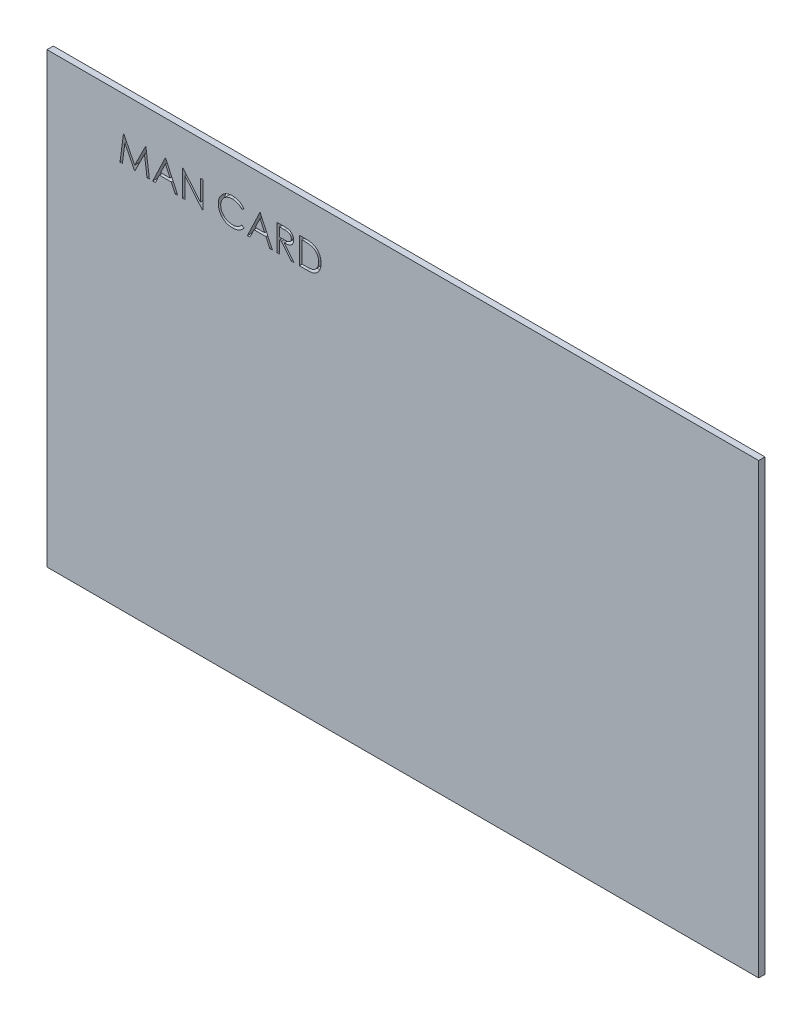
from build123d import *

# Parameters (mm, degrees)
SKETCH1_W           = 85.725
SKETCH1_H           = 53.975
BOSS_EXTRUDE1_DEPTH = 0.75946
CUT_EXTRUDE1_DEPTH  = 0.75946


with BuildPart() as part:
    # Sketch1 → Boss-Extrude1 (new body)
    with BuildSketch(Plane.XY):
        with Locations((-55.690706651, 13.736965558)):
            Rectangle(SKETCH1_W, SKETCH1_H)
    extrude(amount=BOSS_EXTRUDE1_DEPTH)

    # Sketch2 → Cut-Extrude1 (cut)
    with BuildSketch(Plane.XY.offset(0.75946)):
        Polygon((-89.760898959, 33.389305045), (-89.341763342, 36.564305045), (-89.301058213, 36.564305045), (-87.990225882, 33.95917684), (-86.682573638, 36.564305045), (-86.641232492, 36.564305045), (-86.219552805, 33.389305045), (-86.505760737, 33.389305045), (-86.809777164, 35.673880366), (-87.95588093, 33.389305045), (-88.02011871, 33.389305045), (-89.1706746, 35.678968507), (-89.474055008, 33.389305045), align=None)
        Polygon((-84.265706651, 36.564305045), (-82.800322035, 33.389305045), (-83.11006262, 33.389305045), (-83.57944363, 34.40693325), (-85.018751523, 34.40693325), (-85.501488902, 33.389305045), (-85.812501523, 33.389305045), (-84.306411779, 36.564305045), align=None)
        Polygon((-84.289239303, 35.945459893), (-84.864199239, 34.732574276), (-83.72954379, 34.732574276), align=None, mode=Mode.SUBTRACT)
        Polygon((-82.230450241, 33.389305045), (-82.230450241, 36.564305045), (-82.170664584, 36.564305045), (-80.073078446, 34.065391784), (-80.073078446, 36.564305045), (-79.788142548, 36.564305045), (-79.788142548, 33.389305045), (-79.853016346, 33.389305045), (-81.945514343, 35.882494148), (-81.945514343, 33.389305045), align=None)
        with BuildLine():
            Line((-74.822116907, 35.981712898), (-75.071435817, 35.790907609))
            add(Edge.make_bspline(
                [(-75.071435817, 35.790907609), (-75.089221159, 35.812103882), (-75.124552057, 35.854210655), (-75.181392905, 35.913337814), (-75.240630824, 35.968732729), (-75.30224317, 36.020659291), (-75.367338943, 36.067301643), (-75.434341238, 36.111090429), (-75.504370894, 36.150340449), (-75.601209967, 36.197931872), (-75.727890515, 36.247594455), (-75.887361548, 36.289235244), (-76.05383233, 36.315743025), (-76.167404438, 36.318613988), (-76.225171795, 36.320074276)],
                knots=[0, 0, 0, 0, 0.757959112, 1.505699292, 2.245454638, 2.979532153, 3.711538275, 4.438200793, 5.171680507, 5.909471876, 7.393775596, 8.890124382, 10.418191784, 12, 12, 12, 12], degree=3))
            add(Edge.make_bspline(
                [(-76.225171795, 36.320074276), (-76.256997359, 36.319707824), (-76.320353117, 36.318978322), (-76.414377089, 36.30935433), (-76.506645357, 36.295827732), (-76.597097902, 36.275756903), (-76.685619585, 36.250381741), (-76.772789122, 36.220060116), (-76.857344451, 36.182545368), (-76.940455282, 36.141081447), (-77.020083566, 36.094247979), (-77.095426359, 36.043163724), (-77.166208873, 35.988400329), (-77.2324871, 35.92975254), (-77.294328796, 35.867484476), (-77.351285856, 35.800932538), (-77.403161193, 35.730309494), (-77.450983066, 35.656546618), (-77.493811759, 35.579858764), (-77.529671007, 35.499962093), (-77.561425654, 35.418224799), (-77.586552824, 35.333723389), (-77.606441493, 35.247052451), (-77.620164444, 35.157979379), (-77.629678986, 35.066690256), (-77.630404861, 35.004814665), (-77.630770753, 34.973624957)],
                knots=[0, 0, 0, 0, 1.054917814, 2.100044995, 3.131103042, 4.146048494, 5.169673617, 6.183595914, 7.203665975, 8.234915748, 9.262203917, 10.264457458, 11.251630812, 12.227803204, 13.197192746, 14.159520551, 15.12972552, 16.100847026, 17.073214652, 18.039054194, 19.002613845, 19.979014051, 20.95965708, 21.949030935, 22.966165397, 24, 24, 24, 24], degree=3))
            add(Edge.make_bspline(
                [(-77.630770753, 34.973624957), (-77.629626103, 34.92669726), (-77.627378735, 34.83456095), (-77.607377746, 34.699604754), (-77.576983842, 34.570318142), (-77.53143114, 34.447509286), (-77.475261715, 34.329663846), (-77.404286303, 34.218775744), (-77.322084159, 34.113169289), (-77.227492364, 34.015340329), (-77.123709945, 33.925974307), (-77.012360054, 33.847279136), (-76.893720021, 33.781679207), (-76.769099793, 33.727091027), (-76.637540389, 33.685129567), (-76.49927839, 33.655589255), (-76.354614509, 33.636319563), (-76.255763696, 33.634474717), (-76.205455249, 33.633535814)],
                knots=[0, 0, 0, 0, 1.029171465, 2.020641659, 2.987623507, 3.938342917, 4.889210282, 5.84687017, 6.821220943, 7.821438502, 8.827599549, 9.822697543, 10.807740252, 11.797342354, 12.80366471, 13.83203677, 14.896651826, 16, 16, 16, 16], degree=3))
            add(Edge.make_bspline(
                [(-76.205455249, 33.633535814), (-76.150026381, 33.635067779), (-76.040929109, 33.638083051), (-75.880938114, 33.663627513), (-75.727779955, 33.705045767), (-75.581446394, 33.763010311), (-75.442349965, 33.838362393), (-75.310272995, 33.929709754), (-75.185103999, 34.037921313), (-75.109837193, 34.120546722), (-75.071435817, 34.162702481)],
                knots=[0, 0, 0, 0, 1.028121516, 2.023589091, 2.998037872, 3.967518031, 4.937445131, 5.927275754, 6.942489185, 8, 8, 8, 8], degree=3))
            Line((-75.071435817, 34.162702481), (-74.822116907, 33.973805245))
            add(Edge.make_bspline(
                [(-74.822116907, 33.973805245), (-74.842181193, 33.947916793), (-74.882213657, 33.896263891), (-74.947036286, 33.823445983), (-75.015323549, 33.754953037), (-75.087582657, 33.691337266), (-75.162982368, 33.631325715), (-75.242876537, 33.576623339), (-75.326214874, 33.526466609), (-75.412715008, 33.480540756), (-75.502285036, 33.439794396), (-75.59481763, 33.404911335), (-75.689913938, 33.374862328), (-75.787578306, 33.350140928), (-75.888013314, 33.330845017), (-75.99085653, 33.31794574), (-76.096329917, 33.309108432), (-76.167487492, 33.308302966), (-76.203547196, 33.307894789)],
                knots=[0, 0, 0, 0, 0.986787822, 1.968848986, 2.935600012, 3.899624008, 4.868462664, 5.837806735, 6.815139263, 7.798259679, 8.787526145, 9.778297419, 10.776456485, 11.791383307, 12.812564526, 13.85620153, 14.913611965, 16, 16, 16, 16], degree=3))
            add(Edge.make_bspline(
                [(-76.203547196, 33.307894789), (-76.237695379, 33.308132453), (-76.305219184, 33.308602406), (-76.404913052, 33.3162153), (-76.501967886, 33.326601848), (-76.596106296, 33.342241109), (-76.687842002, 33.360696332), (-76.776343389, 33.385435258), (-76.86248133, 33.413147716), (-76.945909754, 33.445718668), (-77.026699624, 33.482472634), (-77.104590367, 33.524012119), (-77.17954616, 33.569987811), (-77.252303934, 33.619386285), (-77.321788885, 33.673794266), (-77.388603155, 33.732456141), (-77.453121401, 33.795174194), (-77.493038122, 33.840399668), (-77.513107492, 33.863138178)],
                knots=[0, 0, 0, 0, 1.114604814, 2.203992996, 3.262667896, 4.300477797, 5.318619304, 6.316056647, 7.298880507, 8.271930387, 9.238335007, 10.195173496, 11.151986948, 12.108099108, 13.064862484, 14.031167946, 15.010108607, 16, 16, 16, 16], degree=3))
            add(Edge.make_bspline(
                [(-77.513107492, 33.863138178), (-77.545252683, 33.902636257), (-77.60915498, 33.981155558), (-77.69091185, 34.108414984), (-77.760895704, 34.241282573), (-77.817479575, 34.380456366), (-77.86171434, 34.525624067), (-77.89235871, 34.676858855), (-77.912271951, 34.834019489), (-77.914549141, 34.94091429), (-77.915706651, 34.995249556)],
                knots=[0, 0, 0, 0, 0.994628077, 1.977248131, 2.950237994, 3.925870899, 4.908910175, 5.911660606, 6.938484602, 8, 8, 8, 8], degree=3))
            add(Edge.make_bspline(
                [(-77.915706651, 34.995249556), (-77.914295868, 35.052359146), (-77.911520241, 35.164718699), (-77.887938341, 35.329613643), (-77.850002719, 35.48759384), (-77.796121256, 35.63836438), (-77.727808544, 35.782718277), (-77.643420116, 35.919552798), (-77.543936351, 36.049743038), (-77.430137486, 36.171313563), (-77.30534426, 36.282474261), (-77.171705051, 36.380269889), (-77.029481427, 36.461656492), (-76.880240233, 36.529688726), (-76.722863936, 36.581980489), (-76.557688309, 36.618586594), (-76.385023722, 36.641371406), (-76.26721995, 36.644251773), (-76.207363301, 36.645715301)],
                knots=[0, 0, 0, 0, 1.032925535, 2.032216505, 3.007276963, 3.968222605, 4.92396291, 5.891752235, 6.871517503, 7.883894988, 8.900124299, 9.891468569, 10.874487609, 11.85992873, 12.854644235, 13.869047385, 14.917252991, 16, 16, 16, 16], degree=3))
            add(Edge.make_bspline(
                [(-76.207363301, 36.645715301), (-76.17088303, 36.645277933), (-76.098674008, 36.644412207), (-75.99185553, 36.635970207), (-75.887858562, 36.621897149), (-75.786611457, 36.602741858), (-75.687621655, 36.578968073), (-75.591645723, 36.547997945), (-75.498120485, 36.512586235), (-75.40763579, 36.471802484), (-75.320625777, 36.42602194), (-75.237117545, 36.375752052), (-75.157774423, 36.321055143), (-75.082038111, 36.262396405), (-75.011175548, 36.198534855), (-74.943174778, 36.131227036), (-74.880345085, 36.05853421), (-74.84156183, 36.007366877), (-74.822116907, 35.981712898)],
                knots=[0, 0, 0, 0, 1.096760587, 2.17092713, 3.219439832, 4.250915756, 5.268269357, 6.278326846, 7.281116186, 8.274029601, 9.260640565, 10.235837813, 11.203064059, 12.156899882, 13.114053108, 14.069676657, 15.032185724, 16, 16, 16, 16], degree=3))
        make_face()
        Polygon((-72.868270753, 36.564305045), (-71.402886138, 33.389305045), (-71.712626723, 33.389305045), (-72.182007733, 34.40693325), (-73.621315625, 34.40693325), (-74.104053005, 33.389305045), (-74.415065625, 33.389305045), (-72.908975882, 36.564305045), align=None)
        Polygon((-72.891803406, 35.945459893), (-73.466763342, 34.732574276), (-72.332107893, 34.732574276), align=None, mode=Mode.SUBTRACT)
        with BuildLine():
            Line((-70.833014343, 36.564305045), (-70.197632733, 36.564305045))
            add(Edge.make_bspline(
                [(-70.197632733, 36.564305045), (-70.155231852, 36.564163906), (-70.073817464, 36.563892904), (-69.95718314, 36.562381819), (-69.851204273, 36.558050797), (-69.755936276, 36.554323725), (-69.671380896, 36.547527464), (-69.597278854, 36.541031734), (-69.533971443, 36.532528484), (-69.49564842, 36.524631422), (-69.478296795, 36.521055846)],
                knots=[0, 0, 0, 0, 1.410062039, 2.707475311, 3.878576406, 4.937260626, 5.877586885, 6.699081471, 7.410979367, 8, 8, 8, 8], degree=3))
            add(Edge.make_bspline(
                [(-69.478296795, 36.521055846), (-69.455067929, 36.515316566), (-69.409105731, 36.503960441), (-69.3429296, 36.479957803), (-69.279870178, 36.452181429), (-69.220189408, 36.419557197), (-69.164186226, 36.381842933), (-69.111283187, 36.339689707), (-69.061240231, 36.293328171), (-69.016081181, 36.241589422), (-68.973500755, 36.187309159), (-68.937588216, 36.128613608), (-68.906630623, 36.067234937), (-68.881983083, 36.002548922), (-68.862136636, 35.935182886), (-68.848142833, 35.864526621), (-68.839750684, 35.790902022), (-68.838896286, 35.74068449), (-68.838463061, 35.715221511)],
                knots=[0, 0, 0, 0, 1.027469482, 2.033020251, 3.019912614, 3.986113645, 4.951240523, 5.91722682, 6.890402269, 7.87763091, 8.8651537, 9.85103654, 10.82876324, 11.815024772, 12.821070561, 13.842952187, 14.906261191, 16, 16, 16, 16], degree=3))
            add(Edge.make_bspline(
                [(-68.838463061, 35.715221511), (-68.839795652, 35.672916809), (-68.842395883, 35.590369378), (-68.86663937, 35.470571293), (-68.906350927, 35.358820986), (-68.961072768, 35.255259165), (-69.030759006, 35.161904508), (-69.114510781, 35.079907452), (-69.212374814, 35.011291246), (-69.303478551, 34.963709058), (-69.383955003, 34.933235491), (-69.450206651, 34.911793937), (-69.522475981, 34.895227726), (-69.600070563, 34.880386749), (-69.683313308, 34.869181998), (-69.772004701, 34.860975444), (-69.866207995, 34.855846414), (-69.930922723, 34.855082596), (-69.964214263, 34.85468966)],
                knots=[0, 0, 0, 0, 1.260483769, 2.459530307, 3.627416485, 4.787058657, 5.939039949, 7.08810263, 8.267026773, 9.491475466, 10.141966685, 10.831826277, 11.566392101, 12.351337768, 13.187381173, 14.07005841, 15.007169909, 16, 16, 16, 16], degree=3))
            Line((-69.964214263, 34.85468966), (-68.797757933, 33.389305045))
            Line((-68.797757933, 33.389305045), (-69.150111699, 33.389305045))
            Line((-69.150111699, 33.389305045), (-70.316568029, 34.85468966))
            Line((-70.316568029, 34.85468966), (-70.548078446, 34.85468966))
            Line((-70.548078446, 34.85468966), (-70.548078446, 33.389305045))
            Line((-70.548078446, 33.389305045), (-70.833014343, 33.389305045))
            Line((-70.833014343, 33.389305045), (-70.833014343, 36.564305045))
        make_face()
        with BuildLine():
            Line((-70.548078446, 36.238664019), (-70.548078446, 35.180330686))
            Line((-70.548078446, 35.180330686), (-69.966758334, 35.175878563))
            add(Edge.make_bspline(
                [(-69.966758334, 35.175878563), (-69.939616584, 35.175866555), (-69.887008143, 35.175843281), (-69.810898254, 35.179466207), (-69.740032153, 35.183587645), (-69.674680899, 35.189891695), (-69.614815298, 35.198016131), (-69.560465274, 35.208178838), (-69.511542105, 35.220018924), (-69.454484145, 35.238344684), (-69.390769578, 35.267378715), (-69.321526039, 35.309620275), (-69.262559633, 35.362750833), (-69.212741286, 35.423505325), (-69.172709587, 35.490303922), (-69.14448651, 35.562345914), (-69.126577294, 35.637812578), (-69.124464971, 35.68968129), (-69.123398959, 35.715857529)],
                knots=[0, 0, 0, 0, 1.146690395, 2.22261258, 3.21895312, 4.145990853, 4.996080663, 5.770904154, 6.481378293, 7.121626537, 8.300444488, 9.431385265, 10.535395872, 11.636531494, 12.74115979, 13.810798291, 14.895190096, 16, 16, 16, 16], degree=3))
            add(Edge.make_bspline(
                [(-69.123398959, 35.715857529), (-69.124489454, 35.741390492), (-69.126650418, 35.791987509), (-69.14429323, 35.866061085), (-69.174128597, 35.935971818), (-69.214335199, 36.001435315), (-69.263320146, 36.060858375), (-69.320758448, 36.11170115), (-69.385079589, 36.153656021), (-69.445197034, 36.180466067), (-69.498930926, 36.196903362), (-69.545584975, 36.208470489), (-69.598300387, 36.217763686), (-69.657333124, 36.22520957), (-69.722431175, 36.231609412), (-69.793923694, 36.235919954), (-69.871336345, 36.238472531), (-69.924991061, 36.238598704), (-69.952765946, 36.238664019)],
                knots=[0, 0, 0, 0, 1.101028733, 2.181837193, 3.264309656, 4.369019818, 5.486613113, 6.575447106, 7.666700264, 8.788928104, 9.402425223, 10.0903467, 10.862060571, 11.710948788, 12.657782767, 13.684531032, 14.801375019, 16, 16, 16, 16], degree=3))
            Line((-69.952765946, 36.238664019), (-70.548078446, 36.238664019))
        make_face(mode=Mode.SUBTRACT)
        with BuildLine():
            Line((-68.146475882, 33.389305045), (-68.146475882, 36.564305045))
            Line((-68.146475882, 36.564305045), (-67.505370112, 36.564305045))
            add(Edge.make_bspline(
                [(-67.505370112, 36.564305045), (-67.449608959, 36.563903571), (-67.3418787, 36.563127925), (-67.186201694, 36.558209948), (-67.042162138, 36.549510026), (-66.910233759, 36.53683767), (-66.790054374, 36.521277418), (-66.681960494, 36.50177348), (-66.585393193, 36.478742782), (-66.526003057, 36.459107267), (-66.497918189, 36.449821872)],
                knots=[0, 0, 0, 0, 1.314313732, 2.53924729, 3.670748893, 4.714932338, 5.66265055, 6.526160246, 7.303039223, 8, 8, 8, 8], degree=3))
            add(Edge.make_bspline(
                [(-66.497918189, 36.449821872), (-66.461183676, 36.435824018), (-66.388547666, 36.408145734), (-66.285126919, 36.355933946), (-66.187767482, 36.296776347), (-66.095947258, 36.230594957), (-66.011763651, 36.155515869), (-65.931927916, 36.07472837), (-65.859705988, 35.985294662), (-65.793567748, 35.889069494), (-65.733936114, 35.787186418), (-65.682102736, 35.679839569), (-65.639055184, 35.567574102), (-65.6033199, 35.450702218), (-65.575156328, 35.328966932), (-65.55594129, 35.202226497), (-65.543267606, 35.070981803), (-65.541993931, 34.98192354), (-65.541347676, 34.936735934)],
                knots=[0, 0, 0, 0, 0.984719456, 1.947108742, 2.898477687, 3.838006223, 4.779231079, 5.722358779, 6.681677486, 7.655904652, 8.64651281, 9.637519902, 10.640069247, 11.656948941, 12.698408672, 13.768548281, 14.867775369, 16, 16, 16, 16], degree=3))
            add(Edge.make_bspline(
                [(-65.541347676, 34.936735934), (-65.54191824, 34.897491811), (-65.543042595, 34.820157167), (-65.553138474, 34.706182926), (-65.567812707, 34.5955899), (-65.590531372, 34.488904729), (-65.618110795, 34.385192703), (-65.653456847, 34.285559167), (-65.693947618, 34.18909014), (-65.741164294, 34.097090001), (-65.792999693, 34.009928657), (-65.848627274, 33.927763713), (-65.907987705, 33.851767619), (-65.971647029, 33.781710235), (-66.038782601, 33.717697175), (-66.109833958, 33.659193704), (-66.184984439, 33.607344543), (-66.263897452, 33.560112238), (-66.348875084, 33.518909487), (-66.441526905, 33.484047978), (-66.542248045, 33.455158548), (-66.650791278, 33.43105495), (-66.767344147, 33.411934826), (-66.892020923, 33.39912017), (-67.02463005, 33.390454295), (-67.115688383, 33.389695567), (-67.162556611, 33.389305045)],
                knots=[0, 0, 0, 0, 1.105936401, 2.179363191, 3.223086493, 4.248585256, 5.251745608, 6.245858792, 7.225916811, 8.198733463, 9.158002045, 10.082870192, 10.993790845, 11.873723703, 12.748670949, 13.606408763, 14.465103618, 15.319838547, 16.196477973, 17.123216899, 18.106603292, 19.147568657, 20.255746949, 21.433717677, 22.679120308, 24, 24, 24, 24], degree=3))
            Line((-67.162556611, 33.389305045), (-68.146475882, 33.389305045))
        make_face()
        with BuildLine():
            Line((-67.861539984, 33.714946071), (-67.497101883, 33.714946071))
            add(Edge.make_bspline(
                [(-67.497101883, 33.714946071), (-67.444734004, 33.71517113), (-67.344011394, 33.715604), (-67.199178782, 33.719402392), (-67.06684533, 33.725609006), (-66.946992246, 33.73429497), (-66.839687203, 33.745787213), (-66.744705944, 33.758600518), (-66.662359817, 33.77456392), (-66.61253097, 33.789033719), (-66.589504728, 33.795720309)],
                knots=[0, 0, 0, 0, 1.375205317, 2.645023457, 3.804390687, 4.853969522, 5.800190428, 6.637939096, 7.370582563, 8, 8, 8, 8], degree=3))
            add(Edge.make_bspline(
                [(-66.589504728, 33.795720309), (-66.560522999, 33.80592708), (-66.50325177, 33.826096833), (-66.420809643, 33.862888426), (-66.343922932, 33.906469446), (-66.271251694, 33.954912937), (-66.2038268, 34.009927525), (-66.140849209, 34.070316922), (-66.082445717, 34.136388468), (-66.029219738, 34.208060157), (-65.981587205, 34.284885901), (-65.940338304, 34.366110414), (-65.904187272, 34.450843735), (-65.87581312, 34.540387043), (-65.853573983, 34.633939832), (-65.83782173, 34.731508682), (-65.82801123, 34.833075374), (-65.826866917, 34.902156229), (-65.826283574, 34.937371952)],
                knots=[0, 0, 0, 0, 0.998632004, 1.973411704, 2.929992603, 3.868527914, 4.809262121, 5.754881198, 6.702106254, 7.672490631, 8.653608572, 9.636854334, 10.631411391, 11.644891563, 12.686317036, 13.754757253, 14.855430412, 16, 16, 16, 16], degree=3))
            add(Edge.make_bspline(
                [(-65.826283574, 34.937371952), (-65.826749199, 34.974504466), (-65.827663923, 35.047451619), (-65.839161333, 35.154486036), (-65.85596303, 35.257429197), (-65.88025966, 35.356287989), (-65.911221243, 35.45125528), (-65.949860668, 35.541805835), (-65.994008244, 35.628895966), (-66.046534842, 35.71051557), (-66.104061845, 35.787707176), (-66.167904635, 35.858423421), (-66.237048913, 35.922825393), (-66.310740526, 35.981916055), (-66.391056324, 36.033318104), (-66.476104315, 36.079298165), (-66.567132173, 36.118319723), (-66.630462262, 36.13907412), (-66.662646755, 36.149621551)],
                knots=[0, 0, 0, 0, 1.122418816, 2.205001699, 3.251619955, 4.274784885, 5.280384055, 6.268708349, 7.249350384, 8.229342522, 9.199999885, 10.157847722, 11.105861043, 12.055065948, 13.010012805, 13.98527497, 14.976112212, 16, 16, 16, 16], degree=3))
            add(Edge.make_bspline(
                [(-66.662646755, 36.149621551), (-66.689272438, 36.156984311), (-66.745885945, 36.172639558), (-66.838268887, 36.18971686), (-66.942241201, 36.204779513), (-67.058264501, 36.217532163), (-67.186206532, 36.226682804), (-67.326165692, 36.233551068), (-67.478202476, 36.238183513), (-67.583596632, 36.238499841), (-67.638297797, 36.238664019)],
                knots=[0, 0, 0, 0, 0.674548936, 1.434276114, 2.292660221, 3.240891867, 4.284742987, 5.42552168, 6.663806718, 8, 8, 8, 8], degree=3))
            Line((-67.638297797, 36.238664019), (-67.861539984, 36.238664019))
            Line((-67.861539984, 36.238664019), (-67.861539984, 33.714946071))
        make_face(mode=Mode.SUBTRACT)
    extrude(amount=-CUT_EXTRUDE1_DEPTH, mode=Mode.SUBTRACT)


with BuildPart() as cut_extrude1_piece_1:
    # of the separate pieces the step leaves, piece 1, a body of its own (cut_extrude1_pieces)
    add(part.part.solids().sort_by_distance((-98.553206651, 40.724465558, 0))[0])


with BuildPart() as cut_extrude1_piece_2:
    # of the separate pieces the step leaves, piece 2, a body of its own (cut_extrude1_pieces)
    add(part.part.solids().sort_by_distance((-67.861539984, 33.714946071, 0))[0])


with BuildPart() as cut_extrude1_piece_3:
    # of the separate pieces the step leaves, piece 3, a body of its own (cut_extrude1_pieces)
    add(part.part.solids().sort_by_distance((-70.548078446, 36.238664019, 0))[0])


with BuildPart() as cut_extrude1_piece_4:
    # of the separate pieces the step leaves, piece 4, a body of its own (cut_extrude1_pieces)
    add(part.part.solids().sort_by_distance((-84.289239303, 35.945459893, 0))[0])


with BuildPart() as cut_extrude1_piece_5:
    # of the separate pieces the step leaves, piece 5, a body of its own (cut_extrude1_pieces)
    add(part.part.solids().sort_by_distance((-72.891803406, 35.945459893, 0))[0])


solid = Compound([cut_extrude1_piece_1.part, cut_extrude1_piece_2.part, cut_extrude1_piece_3.part, cut_extrude1_piece_4.part, cut_extrude1_piece_5.part])
